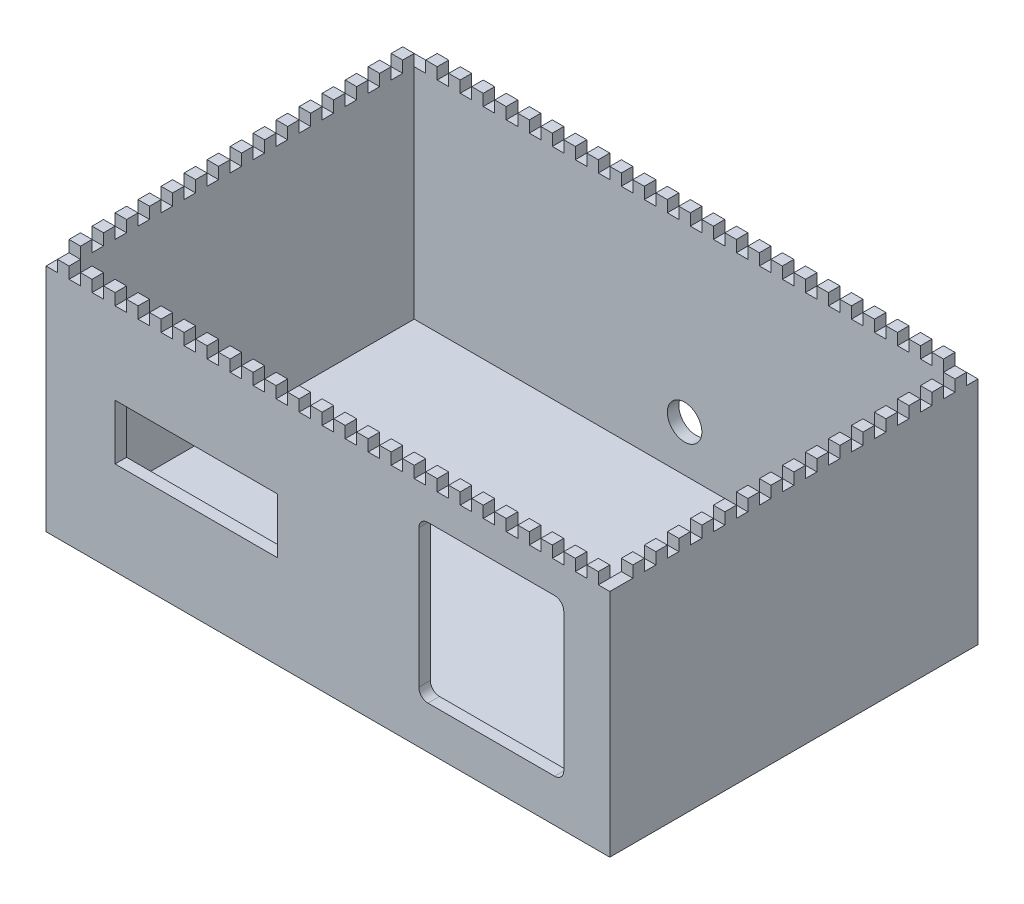
from build123d import *

# Parameters (mm, degrees)
CROQUIS1_W              = 245
CROQUIS1_H              = 160
SALIENTE_EXTRUIR1_DEPTH = 5
CROQUIS2_W              = 245
CROQUIS2_H              = 160
CROQUIS2_W_2            = 235
CROQUIS2_H_2            = 150
SALIENTE_EXTRUIR2_DEPTH = 100
CROQUIS3_W              = 70.5
CROQUIS3_H              = 24
CROQUIS3_W_2            = 63
CROQUIS3_H_2            = 68
CORTAR_EXTRUIR1_DEPTH   = 10
REDONDEO1_R             = 4
CORTAR_EXTRUIR2_DEPTH   = 5
CROQUIS8_R              = 7.5
CORTAR_EXTRUIR3_DEPTH   = 10


with BuildPart() as part:
    # Croquis1 → Saliente-Extruir1 (new body)
    with BuildSketch(Plane(origin=(0, 0, 0), x_dir=(1, 0, 0), z_dir=(0, 1, 0))):
        with Locations((122.5, 80)):
            Rectangle(CROQUIS1_W, CROQUIS1_H)
    extrude(amount=SALIENTE_EXTRUIR1_DEPTH)

    # Croquis2 → Saliente-Extruir2 (add)
    with BuildSketch(Plane(origin=(0, 5, 0), x_dir=(1, 0, 0), z_dir=(0, 1, 0))):
        with Locations((122.5, 80)):
            Rectangle(CROQUIS2_W, CROQUIS2_H)
        with Locations((122.5, 80)):
            Rectangle(CROQUIS2_W_2, CROQUIS2_H_2, mode=Mode.SUBTRACT)
    extrude(amount=SALIENTE_EXTRUIR2_DEPTH)

    # Croquis3 → Cortar-Extruir1 (cut)
    with BuildSketch(Plane.XY):
        with Locations((65.25, 52.5)):
            Rectangle(CROQUIS3_W, CROQUIS3_H)
        with Locations((193.5, 52.5)):
            Rectangle(CROQUIS3_W_2, CROQUIS3_H_2)
    extrude(amount=-CORTAR_EXTRUIR1_DEPTH, mode=Mode.SUBTRACT)

    # Redondeo1
    redondeo1_edges = [part.edges().sort_by_distance(p)[0] for p in [
        (162, 18.5, -2.5),
        (162, 86.5, -2.5),
        (225, 86.5, -2.5),
        (225, 18.5, -2.5),
    ]]
    fillet(redondeo1_edges, radius=REDONDEO1_R)

    # Croquis6 → Cortar-Extruir2 (cut)
    with BuildSketch(Plane(origin=(0, 105, 0), x_dir=(1, 0, 0), z_dir=(0, 1, 0))):
        Polygon((0, 160), (0, 155), (5, 155), (5, 150), (0, 150), (0, 145), (5, 145), (5, 140), (0, 140), (0, 135), (5, 135), (5, 130), (0, 130), (0, 125), (5, 125), (5, 120), (0, 120), (0, 115), (5, 115), (5, 110), (0, 110), (0, 105), (5, 105), (5, 100), (0, 100), (0, 95), (5, 95), (5, 90), (0, 90), (0, 85), (5, 85), (5, 80), (0, 80), (0, 75), (5, 75), (5, 70), (0, 70), (0, 65), (5, 65), (5, 60), (0, 60), (0, 55), (5, 55), (5, 50), (0, 50), (0, 45), (5, 45), (5, 40), (0, 40), (0, 35), (5, 35), (5, 30), (0, 30), (0, 25), (5, 25), (5, 20), (0, 20), (0, 15), (5, 15), (5, 10), (0, 10), (0, 0), (5, 0), (5, 5), (10, 5), (10, 0), (15, 0), (15, 5), (20, 5), (20, 0), (25, 0), (25, 5), (30, 5), (30, 0), (35, 0), (35, 5), (40, 5), (40, 0), (45, 0), (45, 5), (50, 5), (50, 0), (55, 0), (55, 5), (60, 5), (60, 0), (65, 0), (65, 5), (70, 5), (70, 0), (75, 0), (75, 5), (80, 5), (80, 0), (85, 0), (85, 5), (90, 5), (90, 0), (95, 0), (95, 5), (100, 5), (100, 0), (105, 0), (105, 5), (110, 5), (110, 0), (115, 0), (115, 5), (120, 5), (120, 0), (125, 0), (125, 5), (130, 5), (130, 0), (135, 0), (135, 5), (140, 5), (140, 0), (145, 0), (145, 5), (150, 5), (150, 0), (155, 0), (155, 5), (160, 5), (160, 0), (165, 0), (165, 5), (170, 5), (170, 0), (175, 0), (175, 5), (180, 5), (180, 0), (185, 0), (185, 5), (190, 5), (190, 0), (195, 0), (195, 5), (200, 5), (200, 0), (205, 0), (205, 5), (210, 5), (210, 0), (215, 0), (215, 5), (220, 5), (220, 0), (225, 0), (225, 5), (230, 5), (230, 0), (235, 0), (235, 5), (240, 5), (240, 0), (245, 0), (245, 10), (240, 10), (240, 15), (245, 15), (245, 20), (240, 20), (240, 25), (245, 25), (245, 30), (240, 30), (240, 35), (245, 35), (245, 40), (240, 40), (240, 45), (245, 45), (245, 50), (240, 50), (240, 55), (245, 55), (245, 60), (240, 60), (240, 65), (245, 65), (245, 70), (240, 70), (240, 75), (245, 75), (245, 80), (240, 80), (240, 85), (245, 85), (245, 90), (240, 90), (240, 95), (245, 95), (245, 100), (240, 100), (240, 105), (245, 105), (245, 110), (240, 110), (240, 115), (245, 115), (245, 120), (240, 120), (240, 125), (245, 125), (245, 130), (240, 130), (240, 135), (245, 135), (245, 140), (240, 140), (240, 145), (245, 145), (245, 150), (240, 150), (240, 155), (245, 155), (245, 160), (240, 160), (235, 160), (235, 155), (230, 155), (230, 160), (225, 160), (225, 155), (220, 155), (220, 160), (215, 160), (215, 155), (210, 155), (210, 160), (205, 160), (205, 155), (200, 155), (200, 160), (195, 160), (195, 155), (190, 155), (190, 160), (185, 160), (185, 155), (180, 155), (180, 160), (175, 160), (175, 155), (170, 155), (170, 160), (165, 160), (165, 155), (160, 155), (160, 160), (155, 160), (155, 155), (150, 155), (150, 160), (145, 160), (145, 155), (140, 155), (140, 160), (135, 160), (135, 155), (130, 155), (130, 160), (125, 160), (125, 155), (120, 155), (120, 160), (115, 160), (115, 155), (110, 155), (110, 160), (105, 160), (105, 155), (100, 155), (100, 160), (95, 160), (95, 155), (90, 155), (90, 160), (85, 160), (85, 155), (80, 155), (80, 160), (75, 160), (75, 155), (70, 155), (70, 160), (65, 160), (65, 155), (60, 155), (60, 160), (55, 160), (55, 155), (50, 155), (50, 160), (45, 160), (45, 155), (40, 155), (40, 160), (35, 160), (35, 155), (30, 155), (30, 160), (25, 160), (25, 155), (20, 155), (20, 160), (15, 160), (15, 155), (10, 155), (10, 160), align=None)
    extrude(amount=-CORTAR_EXTRUIR2_DEPTH, mode=Mode.SUBTRACT)

    # Croquis8 → Cortar-Extruir3 (cut)
    with BuildSketch(Plane(origin=(0, 0, -160), x_dir=(-1, 0, 0), z_dir=(0, 0, -1))):
        with Locations((-122.5, 25)):
            Circle(CROQUIS8_R)
    extrude(amount=-CORTAR_EXTRUIR3_DEPTH, mode=Mode.SUBTRACT)


solid = part.part
